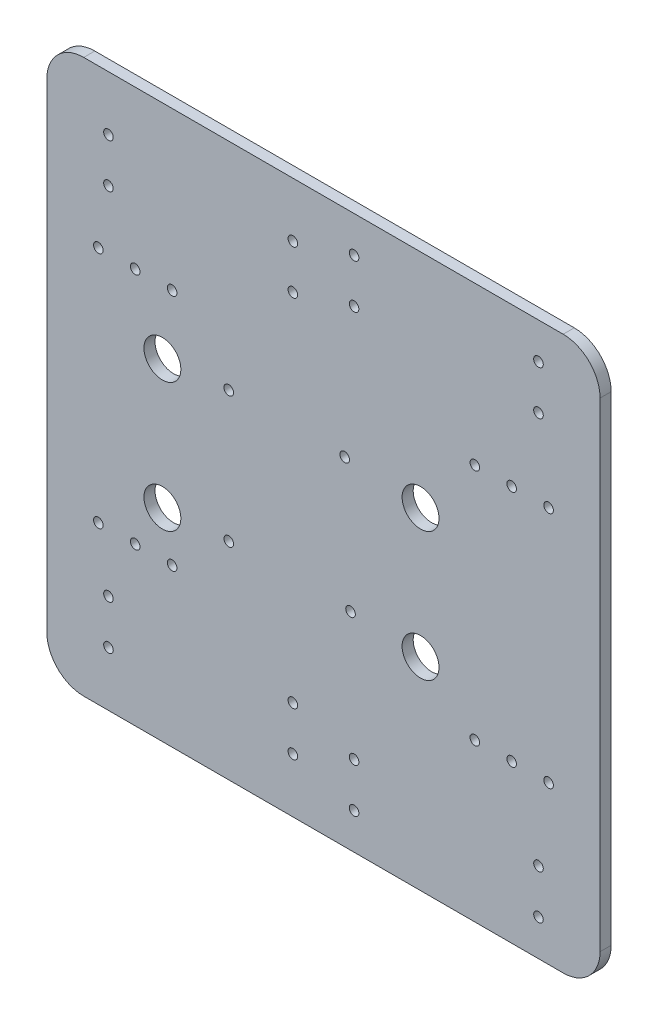
from build123d import *

# Parameters (mm, degrees)
EXTRUDE_1_DEPTH     = 3
SKETCH_8_R          = 1.3
CUT_EXTRUDE_3_DEPTH = 3
CUT_EXTRUDE_7_REACH = 5
SKETCH_15_R         = 1.3
SKETCH_15_R_2       = 5


with BuildPart() as part:
    # 草图1 → 凸台-拉伸1 (new body)
    with BuildSketch(Plane.XY):
        with BuildLine():
            Line((-65, -75), (65, -75))
            ThreePointArc((65, -75), (72.071067812, -72.071067812), (75, -65))
            Line((75, -65), (75, 65))
            ThreePointArc((75, 65), (72.071067812, 72.071067812), (65, 75))
            Line((65, 75), (-65, 75))
            ThreePointArc((-65, 75), (-72.071067812, 72.071067812), (-75, 65))
            Line((-75, 65), (-75, -65))
            ThreePointArc((-75, -65), (-72.071067812, -72.071067812), (-65, -75))
        make_face()
    extrude(amount=EXTRUDE_1_DEPTH)

    # 草图8 → 切除-拉伸3 (cut)
    with BuildSketch(Plane(origin=(0, 0, 0), x_dir=(-1, 0, 0), z_dir=(0, 0, -1))):
        with Locations((8.299978541, 60.2)):
            Circle(SKETCH_8_R)
        with Locations((8.299978541, 48.2)):
            Circle(SKETCH_8_R)
        with Locations((8.299978541, -48.2)):
            Circle(SKETCH_8_R)
        with Locations((8.299978541, -60.2)):
            Circle(SKETCH_8_R)
        with Locations((58.299978541, -48.2)):
            Circle(SKETCH_8_R)
        with Locations((58.299978541, -60.2)):
            Circle(SKETCH_8_R)
        with Locations((58.299978541, 60.2)):
            Circle(SKETCH_8_R)
        with Locations((58.299978541, 48.2)):
            Circle(SKETCH_8_R)
        with Locations((-58.299978541, 65.2)):
            Circle(SKETCH_8_R)
        with Locations((-58.299978541, 53.2)):
            Circle(SKETCH_8_R)
        with Locations((-8.299978541, 53.2)):
            Circle(SKETCH_8_R)
        with Locations((-8.299978541, 65.2)):
            Circle(SKETCH_8_R)
        with Locations((-8.299978541, -65.2)):
            Circle(SKETCH_8_R)
        with Locations((-8.299978541, -53.2)):
            Circle(SKETCH_8_R)
        with Locations((-58.299978541, -53.2)):
            Circle(SKETCH_8_R)
        with Locations((-58.299978541, -65.2)):
            Circle(SKETCH_8_R)
    extrude(amount=-CUT_EXTRUDE_3_DEPTH, mode=Mode.SUBTRACT)

    # 草图15 → 切除-拉伸7 (cut, up to next)
    with BuildSketch(Plane(origin=(0, 0, 0), x_dir=(-1, 0, 0), z_dir=(0, 0, -1)), mode=Mode.PRIVATE) as cut_extrude_7_sk1:
        with Locations((-5.764701549, 16.542565405)):
            Circle(SKETCH_15_R)
    cut_extrude_7_tool1 = extrude(cut_extrude_7_sk1.sketch, amount=-CUT_EXTRUDE_7_REACH, mode=Mode.PRIVATE) & part.part
    add(cut_extrude_7_tool1.solids().sort_by_distance((5.764702, 16.542565, 0))[0], mode=Mode.SUBTRACT)
    # 草图15 → 切除-拉伸7 (cut, up to next)
    with BuildSketch(Plane(origin=(0, 0, 0), x_dir=(-1, 0, 0), z_dir=(0, 0, -1)), mode=Mode.PRIVATE) as cut_extrude_7_sk2:
        with Locations((25.680561341, 16.542565405)):
            Circle(SKETCH_15_R)
    cut_extrude_7_tool2 = extrude(cut_extrude_7_sk2.sketch, amount=-CUT_EXTRUDE_7_REACH, mode=Mode.PRIVATE) & part.part
    add(cut_extrude_7_tool2.solids().sort_by_distance((-25.680561, 16.542565, 0))[0], mode=Mode.SUBTRACT)
    # 草图15 → 切除-拉伸7 (cut, up to next)
    with BuildSketch(Plane(origin=(0, 0, 0), x_dir=(-1, 0, 0), z_dir=(0, 0, -1)), mode=Mode.PRIVATE) as cut_extrude_7_sk3:
        with Locations((25.680561341, -18.966705613)):
            Circle(SKETCH_15_R)
    cut_extrude_7_tool3 = extrude(cut_extrude_7_sk3.sketch, amount=-CUT_EXTRUDE_7_REACH, mode=Mode.PRIVATE) & part.part
    add(cut_extrude_7_tool3.solids().sort_by_distance((-25.680561, -18.966706, 0))[0], mode=Mode.SUBTRACT)
    # 草图15 → 切除-拉伸7 (cut, up to next)
    with BuildSketch(Plane(origin=(0, 0, 0), x_dir=(-1, 0, 0), z_dir=(0, 0, -1)), mode=Mode.PRIVATE) as cut_extrude_7_sk4:
        with Locations((-7.339504699, -18.966705613)):
            Circle(SKETCH_15_R)
    cut_extrude_7_tool4 = extrude(cut_extrude_7_sk4.sketch, amount=-CUT_EXTRUDE_7_REACH, mode=Mode.PRIVATE) & part.part
    add(cut_extrude_7_tool4.solids().sort_by_distance((7.339505, -18.966706, 0))[0], mode=Mode.SUBTRACT)
    # 草图15 → 切除-拉伸7 (cut, up to next)
    with BuildSketch(Plane(origin=(0, 0, 0), x_dir=(-1, 0, 0), z_dir=(0, 0, -1)), mode=Mode.PRIVATE) as cut_extrude_7_sk5:
        with Locations((43.674011713, 14.90502858)):
            Circle(SKETCH_15_R_2)
    cut_extrude_7_tool5 = extrude(cut_extrude_7_sk5.sketch, amount=-CUT_EXTRUDE_7_REACH, mode=Mode.PRIVATE) & part.part
    add(cut_extrude_7_tool5.solids().sort_by_distance((-43.674012, 14.905029, 0))[0], mode=Mode.SUBTRACT)
    # 草图15 → 切除-拉伸7 (cut, up to next)
    with BuildSketch(Plane(origin=(0, 0, 0), x_dir=(-1, 0, 0), z_dir=(0, 0, -1)), mode=Mode.PRIVATE) as cut_extrude_7_sk6:
        with Locations((43.674011713, -20.09497142)):
            Circle(SKETCH_15_R_2)
    cut_extrude_7_tool6 = extrude(cut_extrude_7_sk6.sketch, amount=-CUT_EXTRUDE_7_REACH, mode=Mode.PRIVATE) & part.part
    add(cut_extrude_7_tool6.solids().sort_by_distance((-43.674012, -20.094971, 0))[0], mode=Mode.SUBTRACT)
    # 草图15 → 切除-拉伸7 (cut, up to next)
    with BuildSketch(Plane(origin=(0, 0, 0), x_dir=(-1, 0, 0), z_dir=(0, 0, -1)), mode=Mode.PRIVATE) as cut_extrude_7_sk7:
        with Locations((-26.325988287, 14.90502858)):
            Circle(SKETCH_15_R_2)
    cut_extrude_7_tool7 = extrude(cut_extrude_7_sk7.sketch, amount=-CUT_EXTRUDE_7_REACH, mode=Mode.PRIVATE) & part.part
    add(cut_extrude_7_tool7.solids().sort_by_distance((26.325988, 14.905029, 0))[0], mode=Mode.SUBTRACT)
    # 草图15 → 切除-拉伸7 (cut, up to next)
    with BuildSketch(Plane(origin=(0, 0, 0), x_dir=(-1, 0, 0), z_dir=(0, 0, -1)), mode=Mode.PRIVATE) as cut_extrude_7_sk8:
        with Locations((-26.325988287, -20.09497142)):
            Circle(SKETCH_15_R_2)
    cut_extrude_7_tool8 = extrude(cut_extrude_7_sk8.sketch, amount=-CUT_EXTRUDE_7_REACH, mode=Mode.PRIVATE) & part.part
    add(cut_extrude_7_tool8.solids().sort_by_distance((26.325988, -20.094971, 0))[0], mode=Mode.SUBTRACT)
    # 草图15 → 切除-拉伸7 (cut, up to next)
    with BuildSketch(Plane(origin=(0, 0, 0), x_dir=(-1, 0, 0), z_dir=(0, 0, -1)), mode=Mode.PRIVATE) as cut_extrude_7_sk9:
        with Locations((-51.0383219, 32.287530058)):
            Circle(SKETCH_15_R)
    cut_extrude_7_tool9 = extrude(cut_extrude_7_sk9.sketch, amount=-CUT_EXTRUDE_7_REACH, mode=Mode.PRIVATE) & part.part
    add(cut_extrude_7_tool9.solids().sort_by_distance((51.038322, 32.28753, 0))[0], mode=Mode.SUBTRACT)
    # 草图15 → 切除-拉伸7 (cut, up to next)
    with BuildSketch(Plane(origin=(0, 0, 0), x_dir=(-1, 0, 0), z_dir=(0, 0, -1)), mode=Mode.PRIVATE) as cut_extrude_7_sk10:
        with Locations((51.0383219, 32.287530058)):
            Circle(SKETCH_15_R)
    cut_extrude_7_tool10 = extrude(cut_extrude_7_sk10.sketch, amount=-CUT_EXTRUDE_7_REACH, mode=Mode.PRIVATE) & part.part
    add(cut_extrude_7_tool10.solids().sort_by_distance((-51.038322, 32.28753, 0))[0], mode=Mode.SUBTRACT)
    # 草图15 → 切除-拉伸7 (cut, up to next)
    with BuildSketch(Plane(origin=(0, 0, 0), x_dir=(-1, 0, 0), z_dir=(0, 0, -1)), mode=Mode.PRIVATE) as cut_extrude_7_sk11:
        with Locations((51.0383219, -32.287530058)):
            Circle(SKETCH_15_R)
    cut_extrude_7_tool11 = extrude(cut_extrude_7_sk11.sketch, amount=-CUT_EXTRUDE_7_REACH, mode=Mode.PRIVATE) & part.part
    add(cut_extrude_7_tool11.solids().sort_by_distance((-51.038322, -32.28753, 0))[0], mode=Mode.SUBTRACT)
    # 草图15 → 切除-拉伸7 (cut, up to next)
    with BuildSketch(Plane(origin=(0, 0, 0), x_dir=(-1, 0, 0), z_dir=(0, 0, -1)), mode=Mode.PRIVATE) as cut_extrude_7_sk12:
        with Locations((-51.0383219, -32.287530058)):
            Circle(SKETCH_15_R)
    cut_extrude_7_tool12 = extrude(cut_extrude_7_sk12.sketch, amount=-CUT_EXTRUDE_7_REACH, mode=Mode.PRIVATE) & part.part
    add(cut_extrude_7_tool12.solids().sort_by_distance((51.038322, -32.28753, 0))[0], mode=Mode.SUBTRACT)
    # 草图15 → 切除-拉伸7 (cut, up to next)
    with BuildSketch(Plane(origin=(0, 0, 0), x_dir=(-1, 0, 0), z_dir=(0, 0, -1)), mode=Mode.PRIVATE) as cut_extrude_7_sk13:
        with Locations((-41.0383219, 32.287530058)):
            Circle(SKETCH_15_R)
    cut_extrude_7_tool13 = extrude(cut_extrude_7_sk13.sketch, amount=-CUT_EXTRUDE_7_REACH, mode=Mode.PRIVATE) & part.part
    add(cut_extrude_7_tool13.solids().sort_by_distance((41.038322, 32.28753, 0))[0], mode=Mode.SUBTRACT)
    # 草图15 → 切除-拉伸7 (cut, up to next)
    with BuildSketch(Plane(origin=(0, 0, 0), x_dir=(-1, 0, 0), z_dir=(0, 0, -1)), mode=Mode.PRIVATE) as cut_extrude_7_sk14:
        with Locations((61.0383219, 32.287530058)):
            Circle(SKETCH_15_R)
    cut_extrude_7_tool14 = extrude(cut_extrude_7_sk14.sketch, amount=-CUT_EXTRUDE_7_REACH, mode=Mode.PRIVATE) & part.part
    add(cut_extrude_7_tool14.solids().sort_by_distance((-61.038322, 32.28753, 0))[0], mode=Mode.SUBTRACT)
    # 草图15 → 切除-拉伸7 (cut, up to next)
    with BuildSketch(Plane(origin=(0, 0, 0), x_dir=(-1, 0, 0), z_dir=(0, 0, -1)), mode=Mode.PRIVATE) as cut_extrude_7_sk15:
        with Locations((61.0383219, -32.287530058)):
            Circle(SKETCH_15_R)
    cut_extrude_7_tool15 = extrude(cut_extrude_7_sk15.sketch, amount=-CUT_EXTRUDE_7_REACH, mode=Mode.PRIVATE) & part.part
    add(cut_extrude_7_tool15.solids().sort_by_distance((-61.038322, -32.28753, 0))[0], mode=Mode.SUBTRACT)
    # 草图15 → 切除-拉伸7 (cut, up to next)
    with BuildSketch(Plane(origin=(0, 0, 0), x_dir=(-1, 0, 0), z_dir=(0, 0, -1)), mode=Mode.PRIVATE) as cut_extrude_7_sk16:
        with Locations((-41.0383219, -32.287530058)):
            Circle(SKETCH_15_R)
    cut_extrude_7_tool16 = extrude(cut_extrude_7_sk16.sketch, amount=-CUT_EXTRUDE_7_REACH, mode=Mode.PRIVATE) & part.part
    add(cut_extrude_7_tool16.solids().sort_by_distance((41.038322, -32.28753, 0))[0], mode=Mode.SUBTRACT)
    # 草图15 → 切除-拉伸7 (cut, up to next)
    with BuildSketch(Plane(origin=(0, 0, 0), x_dir=(-1, 0, 0), z_dir=(0, 0, -1)), mode=Mode.PRIVATE) as cut_extrude_7_sk17:
        with Locations((-61.0383219, -32.287530058)):
            Circle(SKETCH_15_R)
    cut_extrude_7_tool17 = extrude(cut_extrude_7_sk17.sketch, amount=-CUT_EXTRUDE_7_REACH, mode=Mode.PRIVATE) & part.part
    add(cut_extrude_7_tool17.solids().sort_by_distance((61.038322, -32.28753, 0))[0], mode=Mode.SUBTRACT)
    # 草图15 → 切除-拉伸7 (cut, up to next)
    with BuildSketch(Plane(origin=(0, 0, 0), x_dir=(-1, 0, 0), z_dir=(0, 0, -1)), mode=Mode.PRIVATE) as cut_extrude_7_sk18:
        with Locations((41.0383219, -32.287530058)):
            Circle(SKETCH_15_R)
    cut_extrude_7_tool18 = extrude(cut_extrude_7_sk18.sketch, amount=-CUT_EXTRUDE_7_REACH, mode=Mode.PRIVATE) & part.part
    add(cut_extrude_7_tool18.solids().sort_by_distance((-41.038322, -32.28753, 0))[0], mode=Mode.SUBTRACT)
    # 草图15 → 切除-拉伸7 (cut, up to next)
    with BuildSketch(Plane(origin=(0, 0, 0), x_dir=(-1, 0, 0), z_dir=(0, 0, -1)), mode=Mode.PRIVATE) as cut_extrude_7_sk19:
        with Locations((41.0383219, 32.287530058)):
            Circle(SKETCH_15_R)
    cut_extrude_7_tool19 = extrude(cut_extrude_7_sk19.sketch, amount=-CUT_EXTRUDE_7_REACH, mode=Mode.PRIVATE) & part.part
    add(cut_extrude_7_tool19.solids().sort_by_distance((-41.038322, 32.28753, 0))[0], mode=Mode.SUBTRACT)
    # 草图15 → 切除-拉伸7 (cut, up to next)
    with BuildSketch(Plane(origin=(0, 0, 0), x_dir=(-1, 0, 0), z_dir=(0, 0, -1)), mode=Mode.PRIVATE) as cut_extrude_7_sk20:
        with Locations((-61.0383219, 32.287530058)):
            Circle(SKETCH_15_R)
    cut_extrude_7_tool20 = extrude(cut_extrude_7_sk20.sketch, amount=-CUT_EXTRUDE_7_REACH, mode=Mode.PRIVATE) & part.part
    add(cut_extrude_7_tool20.solids().sort_by_distance((61.038322, 32.28753, 0))[0], mode=Mode.SUBTRACT)


solid = part.part
